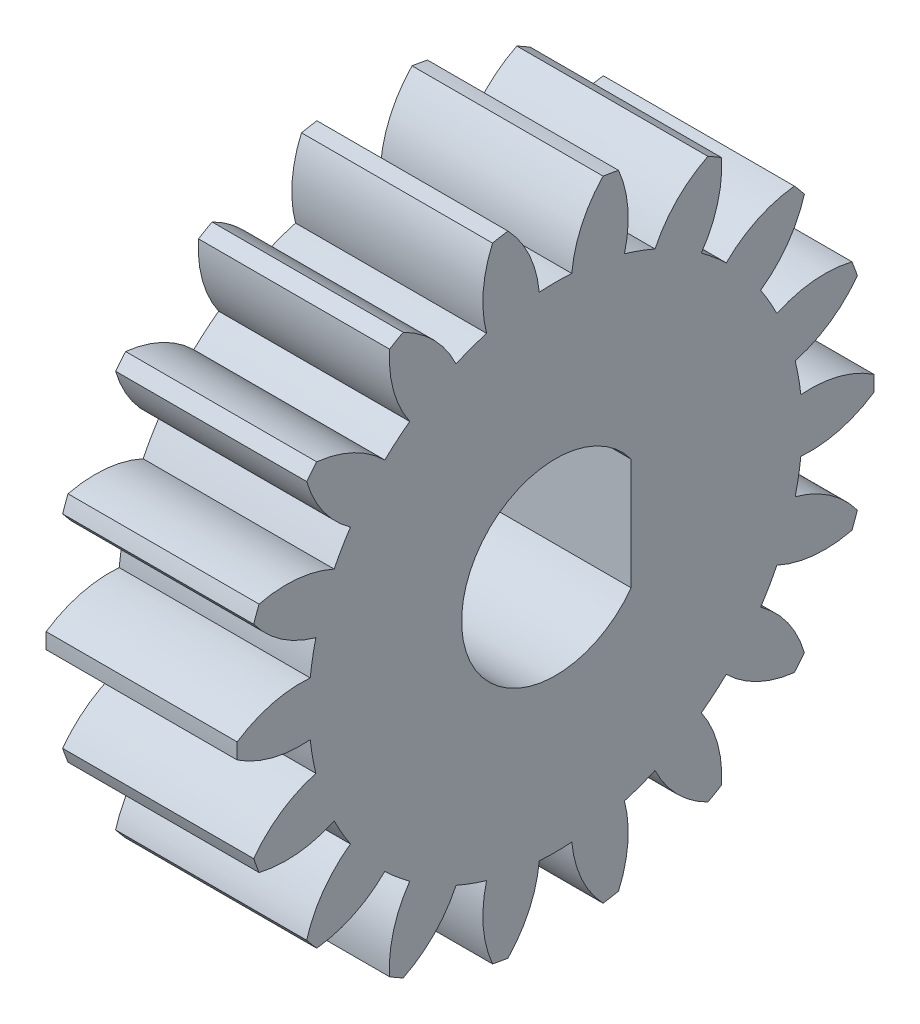
from build123d import *

# Parameters (mm, degrees)
BASPROSKE_W        = 6
BASPROSKE_H        = 10
TOOTHCUT_DEPTH     = 16.362291496
TEETHCUTS_COUNT    = 18
TEETHCUTS_ANGLE    = 340
CUT_EXTRUDE1_DEPTH = 16.289512146


with BuildPart() as part:
    # BasProSke → Base-Revolve (revolve)
    with BuildSketch(Plane(origin=(0, 0, 0), x_dir=(1, 0, 0), z_dir=(0, 1, 0)), mode=Mode.PRIVATE) as base_revolve_sk:
        with Locations((3, 5)):
            Rectangle(BASPROSKE_W, BASPROSKE_H)
    revolve(base_revolve_sk.sketch.rotate(Axis((-10, 0, 0), (1, 0, 0)), 180), axis=Axis((-10, 0, 0), (1, 0, 0)))

    # TooCutSke → ToothCut (cut, through all)
    with BuildSketch(Plane(origin=(0, 0, 0), x_dir=(0, 0, -1), z_dir=(1, 0, 0))):
        with BuildLine():
            ThreePointArc((0.510641536, 7.732156635), (0, 7.749), (-0.510641536, 7.732156635))
            ThreePointArc((-0.510641536, 7.732156635), (-0.82619259, 8.907320741), (-1.515208602, 9.910236529))
            ThreePointArc((-1.515208602, 9.910236529), (0, 10.0254), (1.515208602, 9.910236529))
            ThreePointArc((1.515208602, 9.910236529), (0.82619259, 8.907320741), (0.510641536, 7.732156635))
        make_face()
    toothcut = extrude(amount=TOOTHCUT_DEPTH, mode=Mode.SUBTRACT)

    # TeethCuts: ToothCut ×18 about axis
    teethcuts_axis = Axis((-10, 0, 0), (1, 0, 0))
    for i in range(1, TEETHCUTS_COUNT):
        add(toothcut.rotate(teethcuts_axis, i * TEETHCUTS_ANGLE / (TEETHCUTS_COUNT - 1)), mode=Mode.SUBTRACT)

    # Sketch1 → Cut-Extrude1 (cut, through all)
    with BuildSketch(Plane(origin=(6, 0, 0), x_dir=(0, 0, -1), z_dir=(1, 0, 0))):
        with BuildLine():
            Line((2.374868417, 1.75), (2.374868417, -1.75))
            ThreePointArc((2.374868417, -1.75), (-2.95, 0), (2.374868417, 1.75))
        make_face()
    extrude(amount=-CUT_EXTRUDE1_DEPTH, mode=Mode.SUBTRACT)


solid = part.part
